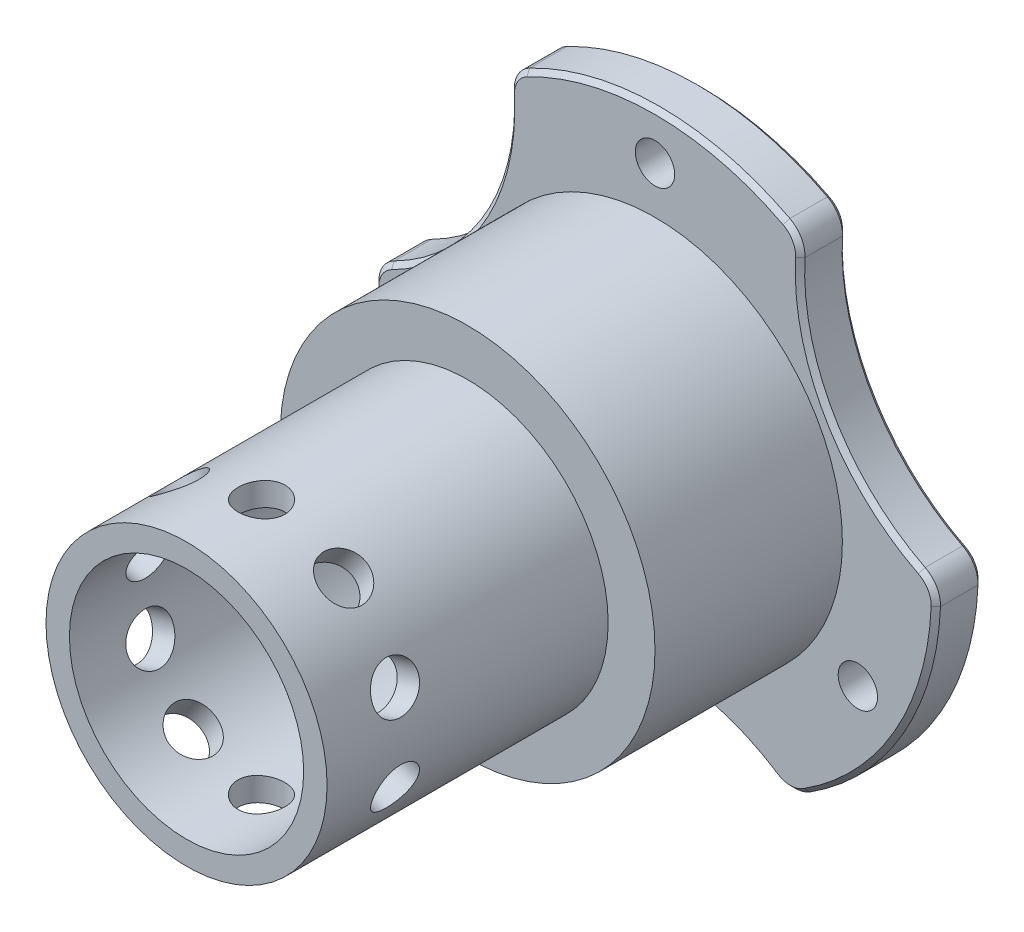
from build123d import *

# Parameters (mm, degrees)
EXTRUDE_1_DEPTH          = 5
SKETCH_2_R               = 2.1
CUT_EXTRUDE_1_DEPTH      = 5
SKETCH_3_R               = 20
EXTRUDE_2_DEPTH          = 50
SKETCH_4_R               = 15.5
CUT_EXTRUDE_2_DEPTH      = 12
SKETCH_9_R               = 20
SKETCH_9_R_2             = 15
CUT_EXTRUDE_7_DEPTH      = 30
FILLET_1_R               = 3
CHAMFER_1_SIZE           = 0.5
CHAMFER_2_SIZE           = 3
CUT_EXTRUDE_START        = -31.0000001
SKETCH_12_R              = 2.5
CUT_EXTRUDE_8_DEPTH      = 57.797222422
SKETCH_14_R              = 12.5
CUT_EXTRUDE_9_DEPTH      = 42
SKETCH_15_R              = 7.5
CUT_EXTRUDE_10_DEPTH     = 14.0000001
PATTERN_CIRCULAR_2_COUNT = 5


with BuildPart() as part:
    # ｽｹｯﾁ1 → ﾎﾞｽ - 押し出し1 (new body)
    with BuildSketch(Plane.XY):
        with BuildLine():
            ThreePointArc((14.315912917, -26.363888889), (25.782526908, -15.338230219), (30, 0))
            ThreePointArc((30, 0), (29.997438385, 0.392033564), (29.989753979, 0.78400018))
            ThreePointArc((29.989753979, 0.78400018), (18.619546181, 10.75), (15.673841062, 25.579888709))
            ThreePointArc((15.673841062, 25.579888709), (0, 30), (-15.673841062, 25.579888709))
            ThreePointArc((-15.673841062, 25.579888709), (-18.619546181, 10.75), (-29.989753979, 0.78400018))
            ThreePointArc((-29.989753979, 0.78400018), (-25.980762114, -15), (-14.315912917, -26.363888889))
            ThreePointArc((-14.315912917, -26.363888889), (0, -21.5), (14.315912917, -26.363888889))
        make_face()
    extrude(amount=EXTRUDE_1_DEPTH)

    # ｽｹｯﾁ2 → ｶｯﾄ - 押し出し1 (cut)
    with BuildSketch(Plane(origin=(0, 0, 0), x_dir=(-1, 0, 0), z_dir=(0, 0, -1))):
        with Locations((0, 25)):
            Circle(SKETCH_2_R)
        with Locations((-21.650635095, -12.5)):
            Circle(SKETCH_2_R)
        with Locations((21.650635095, -12.5)):
            Circle(SKETCH_2_R)
    extrude(amount=-CUT_EXTRUDE_1_DEPTH, mode=Mode.SUBTRACT)

    # ｽｹｯﾁ3 → ﾎﾞｽ - 押し出し2 (add)
    with BuildSketch(Plane.XY.offset(5)):
        Circle(SKETCH_3_R)
    extrude(amount=EXTRUDE_2_DEPTH)

    # ｽｹｯﾁ4 → ｶｯﾄ - 押し出し2 (cut)
    with BuildSketch(Plane(origin=(0, 0, 0), x_dir=(-1, 0, 0), z_dir=(0, 0, -1))):
        Circle(SKETCH_4_R)
    extrude(amount=-CUT_EXTRUDE_2_DEPTH, mode=Mode.SUBTRACT)

    # ｽｹｯﾁ9 → ｶｯﾄ - 押し出し7 (cut)
    with BuildSketch(Plane.XY.offset(55)):
        Circle(SKETCH_9_R)
        Circle(SKETCH_9_R_2, mode=Mode.SUBTRACT)
    extrude(amount=-CUT_EXTRUDE_7_DEPTH, mode=Mode.SUBTRACT)

    # ﾌｨﾚｯﾄ1
    fillet_1_edges = [part.edges().sort_by_distance(p)[0] for p in [
        (-14.315912917, -26.363888889, 2.5),
        (-29.989753979, 0.78400018, 2.5),
        (-15.673841062, 25.579888709, 2.5),
        (15.673841062, 25.579888709, 2.5),
        (29.989753979, 0.78400018, 2.5),
        (14.315912917, -26.363888889, 2.5),
    ]]
    fillet(fillet_1_edges, radius=FILLET_1_R)

    # 面取り1
    chamfer_1_edges = [part.edges().sort_by_distance(p)[0] for p in [
        (0, -21.5, 0),
        (0, -21.5, 5),
        (-25.980762114, -15, 0),
        (-18.619546181, 10.75, 0),
        (0, 30, 0),
        (18.619546181, 10.75, 0),
        (25.980762114, -15, 0),
        (14.44871421, -25.797168048, 0),
        (29.56535998, 0.385630466, 0),
        (15.11664577, 25.411537582, 0),
        (-15.11664577, 25.411537582, 0),
        (-29.56535998, 0.385630466, 0),
        (-14.44871421, -25.797168048, 0),
        (-25.980762114, -15, 5),
        (25.980762114, -15, 5),
        (18.619546181, 10.75, 5),
        (0, 30, 5),
        (-18.619546181, 10.75, 5),
        (14.44871421, -25.797168048, 5),
        (29.56535998, 0.385630466, 5),
        (15.11664577, 25.411537582, 5),
        (-15.11664577, 25.411537582, 5),
        (-29.56535998, 0.385630466, 5),
        (-14.44871421, -25.797168048, 5),
    ]]
    chamfer(chamfer_1_edges, length=CHAMFER_1_SIZE)

    # 面取り2
    chamfer_2_edges = [part.edges().sort_by_distance(p)[0] for p in [
        (15.5, 0, 0),
    ]]
    chamfer(chamfer_2_edges, length=CHAMFER_2_SIZE)

    # ｽｹｯﾁ12 → ｶｯﾄ - 押し出し8 (cut)
    with BuildSketch(Plane(origin=(0, 0, 47), x_dir=(-1, 0, 0), z_dir=(0, -1, 0)).offset(CUT_EXTRUDE_START)):
        Circle(SKETCH_12_R)
    cut_extrude_8 = extrude(amount=CUT_EXTRUDE_8_DEPTH, mode=Mode.SUBTRACT)

    # ｽｹｯﾁ14 → ｶｯﾄ - 押し出し9 (cut)
    with BuildSketch(Plane.XY.offset(55)):
        Circle(SKETCH_14_R)
    extrude(amount=-CUT_EXTRUDE_9_DEPTH, mode=Mode.SUBTRACT)

    # ｽｹｯﾁ15 → ｶｯﾄ - 押し出し10 (cut, through all)
    with BuildSketch(Plane.XY.offset(13)):
        Circle(SKETCH_15_R)
    extrude(amount=-CUT_EXTRUDE_10_DEPTH, mode=Mode.SUBTRACT)

    # 円形ﾊﾟﾀｰﾝ2: ｶｯﾄ - 押し出し8 ×5 about axis
    pattern_circular_2_axis = Axis((0, 0, 13), (0, 0, 1))
    for i in range(1, PATTERN_CIRCULAR_2_COUNT):
        add(cut_extrude_8.rotate(pattern_circular_2_axis, i * 360 / PATTERN_CIRCULAR_2_COUNT), mode=Mode.SUBTRACT)


solid = part.part
